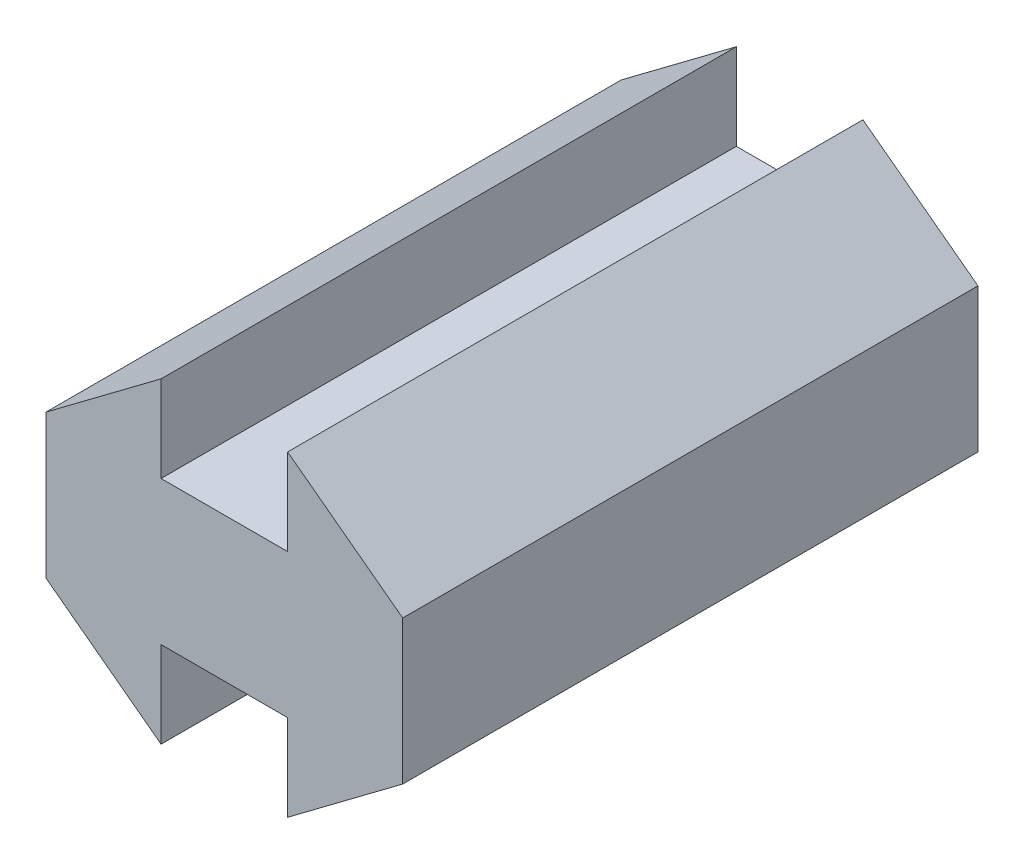
from build123d import *

# Parameters (mm, degrees)
BOSS_EXTRU_1_DEPTH = 20


with BuildPart() as part:
    # ProfileRainureEsquisse → Boss.-Extru.1 (new body)
    with BuildSketch(Plane.XY):
        Polygon((0, 0), (0, 5), (4, 8), (4, 5), (8.4, 5), (8.4, 8), (12.4, 5), (12.4, 0), (8.4, -3), (8.4, 0), (4, 0), (4, -3), align=None)
    extrude(amount=BOSS_EXTRU_1_DEPTH)


solid = part.part
